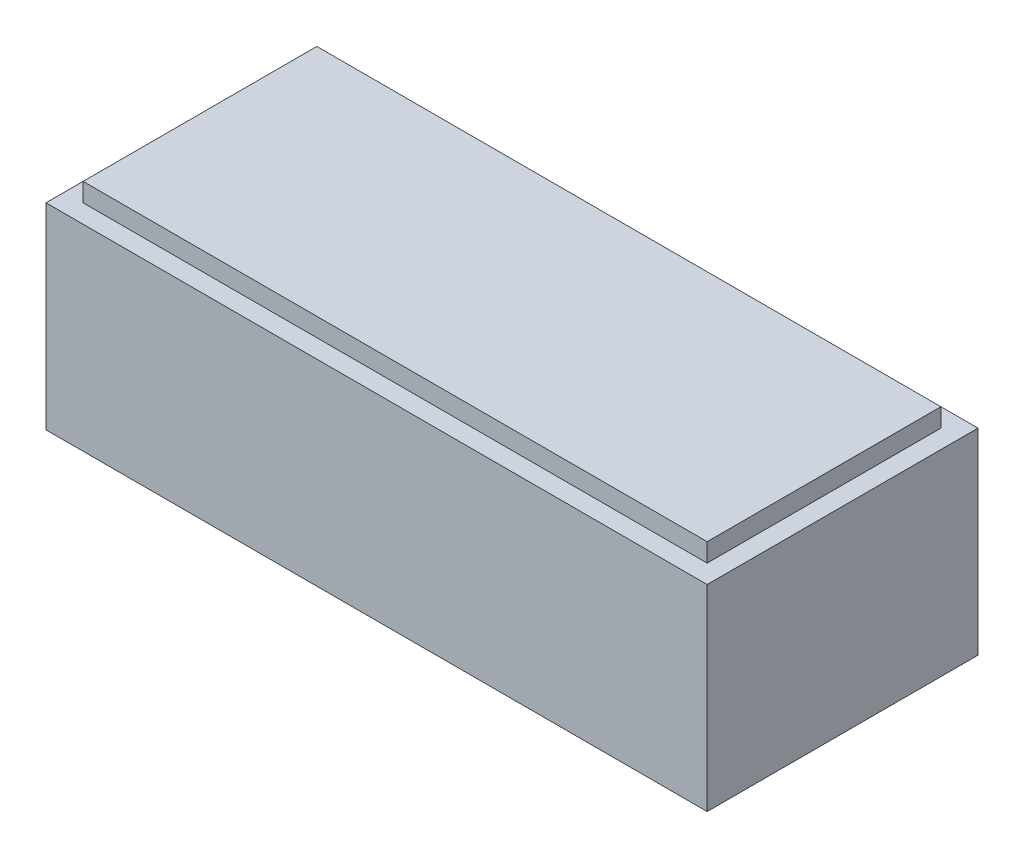
from build123d import *

# Parameters (mm, degrees)
SKETCH1_W          = 8.91
SKETCH1_H          = 3.65
MAIN_SHAPE_DEPTH   = 2.65
SKETCH2_W          = 8.41
SKETCH2_H          = 3.15
BOTTOM_BASE_DEPTH  = 0.25
SWITCH_HOLE_W      = 3.91
SWITCH_HOLE_H      = 1.7
CUT_EXTRUDE1_DEPTH = 0.5


with BuildPart() as part:
    # Sketch1 → main shape (new body)
    with BuildSketch(Plane(origin=(0, 0, 0), x_dir=(1, 0, 0), z_dir=(0, 1, 0))):
        with Locations((4.455, 1.825)):
            Rectangle(SKETCH1_W, SKETCH1_H)
    extrude(amount=MAIN_SHAPE_DEPTH)

    # Sketch2 → bottom base (add)
    with BuildSketch(Plane(origin=(0, 2.65, 0), x_dir=(1, 0, 0), z_dir=(0, 1, 0))):
        with Locations((4.455, 1.825)):
            Rectangle(SKETCH2_W, SKETCH2_H)
    extrude(amount=BOTTOM_BASE_DEPTH)

    # switch hole → Cut-Extrude1 (cut)
    with BuildSketch(Plane.XZ):
        with Locations((4.455, -1.825)):
            Rectangle(SWITCH_HOLE_W, SWITCH_HOLE_H)
    extrude(amount=-CUT_EXTRUDE1_DEPTH, mode=Mode.SUBTRACT)


solid = part.part
